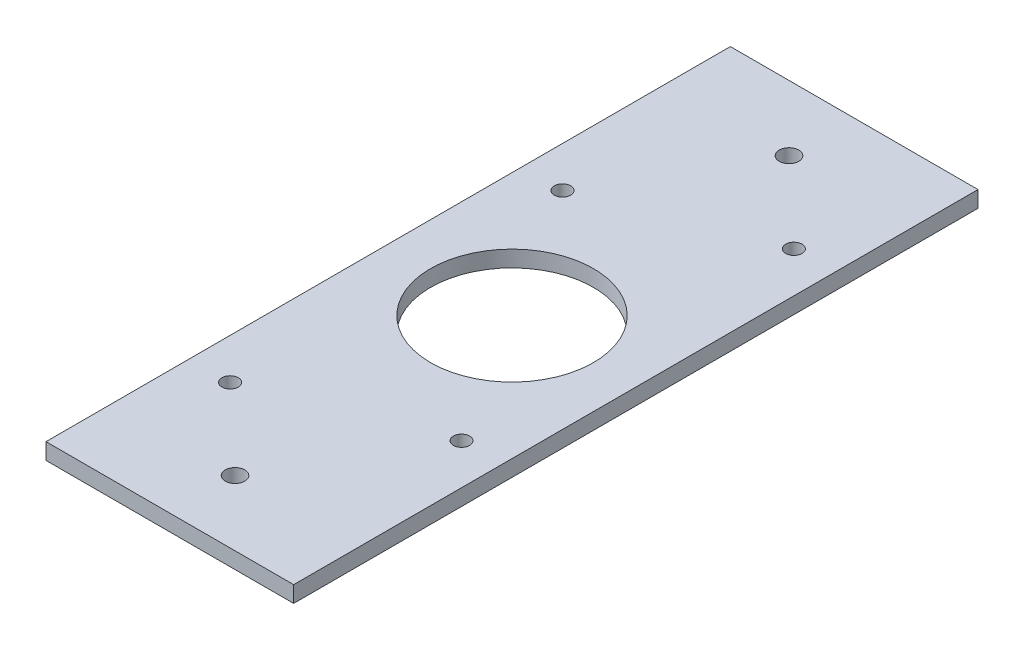
from build123d import *

# Parameters (mm, degrees)
SKETCH1_W           = 76
SKETCH1_H           = 210
SKETCH1_R           = 3
SKETCH1_R_2         = 2.5
SKETCH1_R_3         = 25
BOSS_EXTRUDE1_DEPTH = 5


with BuildPart() as part:
    # Sketch1 → Boss-Extrude1 (new body)
    with BuildSketch(Plane(origin=(0, 0, 0), x_dir=(1, 0, 0), z_dir=(0, 1, 0))):
        with Locations((-31.026205917, -6.39064)):
            Rectangle(SKETCH1_W, SKETCH1_H)
        with Locations((-31.026205917, 78.60936)):
            Circle(SKETCH1_R, mode=Mode.SUBTRACT)
        with Locations((-31.026205917, -91.39064)):
            Circle(SKETCH1_R, mode=Mode.SUBTRACT)
        with Locations((-56.526205917, 34.60936)):
            Circle(SKETCH1_R_2, mode=Mode.SUBTRACT)
        with Locations((-5.526205917, 54.60936)):
            Circle(SKETCH1_R_2, mode=Mode.SUBTRACT)
        with Locations((-56.526205917, -67.39064)):
            Circle(SKETCH1_R_2, mode=Mode.SUBTRACT)
        with Locations((-5.526205917, -47.39064)):
            Circle(SKETCH1_R_2, mode=Mode.SUBTRACT)
        with Locations((-31.026205917, -6.39064)):
            Circle(SKETCH1_R_3, mode=Mode.SUBTRACT)
    extrude(amount=BOSS_EXTRUDE1_DEPTH)


solid = part.part
